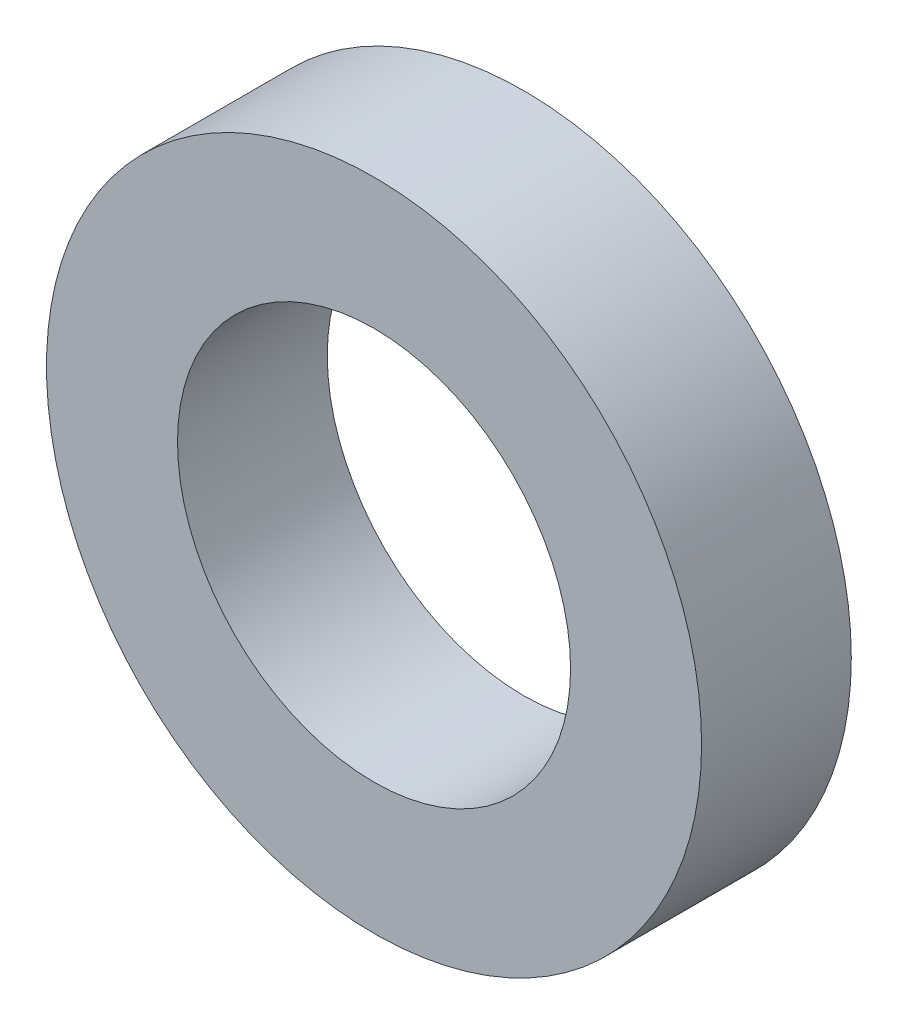
from build123d import *

# Parameters (mm, degrees)
ESQUISSE1_R        = 1.75
ESQUISSE1_R_2      = 1.05
BOSS_EXTRU_1_DEPTH = 0.4


with BuildPart() as part:
    # Esquisse1 → Boss.-Extru.1 (new body, symmetric)
    with BuildSketch(Plane.XY):
        Circle(ESQUISSE1_R)
        Circle(ESQUISSE1_R_2, mode=Mode.SUBTRACT)
    extrude(amount=BOSS_EXTRU_1_DEPTH, both=True)


solid = part.part
